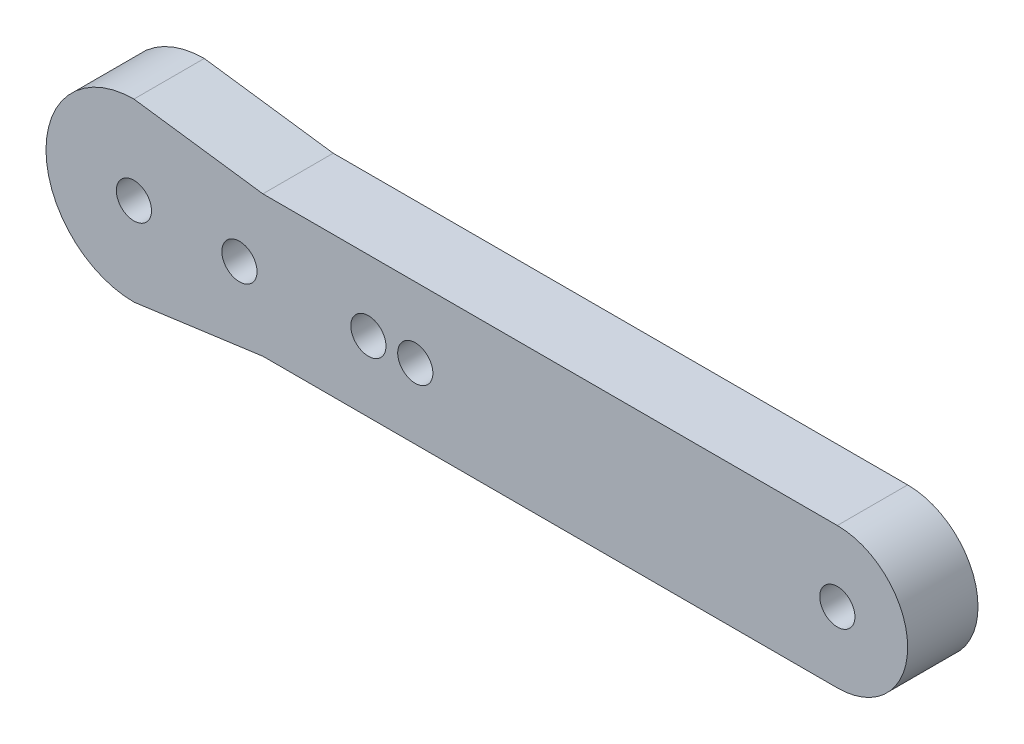
from build123d import *

# Parameters (mm, degrees)
EXTRUDE_1_DEPTH    = 6
HOLE_WIZARD_M3_1_D = 3
EXTRUDE_3_DEPTH    = 6


with BuildPart() as part:
    # 草图1 → 凸台-拉伸1 (new body)
    with BuildSketch(Plane.XY):
        with BuildLine():
            Line((0, 6), (60, 6))
            ThreePointArc((60, 6), (66, 0), (60, -6))
            Line((60, -6), (0, -6))
            ThreePointArc((0, -6), (-6, 0), (0, 6))
        make_face()
    extrude(amount=EXTRUDE_1_DEPTH)

    # M3 螺纹孔1 (through all)
    with Locations(Plane.XY.offset(6)):
        with Locations((0, 0), (60, 0), (9, 0), (20, 0), (24, 0)):
            Hole(HOLE_WIZARD_M3_1_D / 2)

    # 草图4 → 凸台-拉伸3 (add)
    with BuildSketch(Plane.XY):
        with BuildLine():
            Line((0, 7.5), (11, 6))
            Line((11, 6), (0, 6))
            ThreePointArc((0, 6), (-6, 0), (0, -6))
            Line((0, -6), (11, -6))
            Line((11, -6), (0, -7.5))
            ThreePointArc((0, -7.5), (-7.5, 0), (0, 7.5))
        make_face()
    extrude(amount=EXTRUDE_3_DEPTH)


solid = part.part
